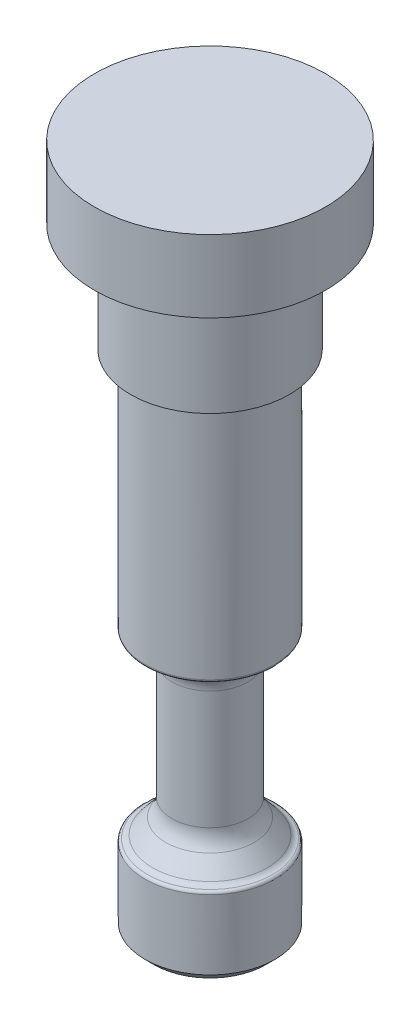
from build123d import *

# Parameters (mm, degrees)
SKETCH1_R               = 5.715
MAIN_DEPTH              = 44.45
CHAMFER1_SIZE           = 0.79375
FILLET1_R               = 0.254
SKETCH6_R               = 6.985
SPRING_STABILIZER_DEPTH = 9.525
SKETCH3_R               = 10.16
TOP_CAP_DEPTH           = 6.35
FILLET2_R               = 1.27


with BuildPart() as part:
    # Sketch1 → main (new body)
    with BuildSketch(Plane(origin=(0, 0, 0), x_dir=(1, 0, 0), z_dir=(0, 1, 0))):
        Circle(SKETCH1_R)
    extrude(amount=MAIN_DEPTH)

    # Chamfer1
    chamfer1_edges = [part.edges().sort_by_distance(p)[0] for p in [
        (-5.715, 0, 0),
    ]]
    chamfer(chamfer1_edges, length=CHAMFER1_SIZE)

    # Sketch2 → Cut-Revolve1 (revolve, cut)
    with BuildSketch(Plane(origin=(0, 0, 0), x_dir=(0, 0, -1), z_dir=(1, 0, 0))):
        with BuildLine():
            Line((-3.89085667, 8.788112004), (-5.032724148, 7.427287335))
            ThreePointArc((-5.032724148, 7.427287335), (-5.30531868, 7.218118194), (-5.640771925, 7.14375))
            Line((-5.640771925, 7.14375), (-5.715, 7.14375))
            Line((-5.715, 7.14375), (-5.715, 23.01875))
            Line((-5.715, 23.01875), (-5.61975, 23.01875))
            ThreePointArc((-5.61975, 23.01875), (-4.003303898, 22.349196102), (-3.33375, 20.73275))
            Line((-3.33375, 20.73275), (-3.33375, 10.31875))
            ThreePointArc((-3.33375, 10.31875), (-3.477356947, 9.504314534), (-3.89085667, 8.788112004))
        make_face()
    revolve(axis=Axis((0, 44.45, 0), (0, -1, 0)), mode=Mode.SUBTRACT)

    # Fillet1
    fillet1_edges = [part.edges().sort_by_distance(p)[0] for p in [
        (-5.715, 7.14375, 0),
        (-5.715, 23.01875, 0),
    ]]
    fillet(fillet1_edges, radius=FILLET1_R)

    # Sketch6 → spring_stabilizer (add)
    with BuildSketch(Plane(origin=(0, 44.45, 0), x_dir=(1, 0, 0), z_dir=(0, 1, 0))):
        Circle(SKETCH6_R)
    extrude(amount=SPRING_STABILIZER_DEPTH)

    # Sketch3 → top_cap (add)
    with BuildSketch(Plane(origin=(0, 53.975, 0), x_dir=(1, 0, 0), z_dir=(0, 1, 0))):
        Circle(SKETCH3_R)
    extrude(amount=TOP_CAP_DEPTH)

    # Fillet2
    fillet2_edges = [part.edges().sort_by_distance(p)[0] for p in [
        (-6.985, 53.975, 0),
    ]]
    fillet(fillet2_edges, radius=FILLET2_R)


solid = part.part
